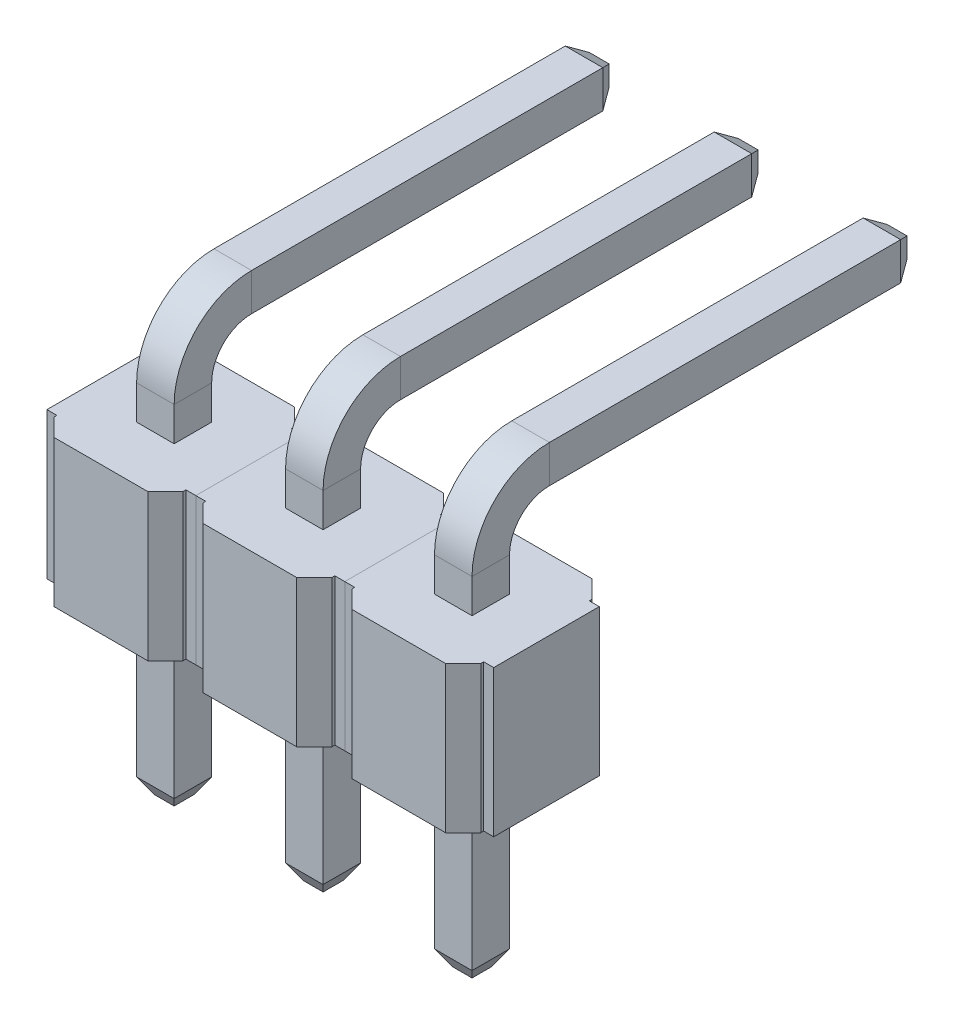
from build123d import *

# Parameters (mm, degrees)
SKETCH_3_W                   = 0.64
SKETCH_3_H                   = 0.64
END_PIN_PROFILE_SIZE         = 0.15
END_PIN_PROFILE_SIZE2        = 0.259807621
END_PIN_PROFILE_PART_2_SIZE  = 0.15
END_PIN_PROFILE_PART_2_SIZE2 = 0.259807621
BASE_BODY_DEPTH              = 2.5
BB_CHAMFER_SIZE              = 0.3
LP_ALL_COUNT                 = 2
LP_ALL_PITCH                 = 2.54
LP_ALL_2_COUNT               = 2
LP_ALL_2_PITCH               = 2.54


with BuildPart() as part:
    # PIN PROFILE: sweep along a path in Эскиз2
    with BuildLine(Plane(origin=(0, 0, 0), x_dir=(0, 0, -1), z_dir=(1, 0, 0))) as pin_profile_path:
        Line((0, -3), (0, 0))
        Line((0, 0), (0, 3.08))
        ThreePointArc((0, 3.08), (0.292893219, 3.787106781), (1, 4.08))
        Line((1, 4.08), (7.25, 4.08))
    # Эскиз3 → PIN PROFILE (sweep)
    with BuildSketch(Plane(origin=(0, 0, 0), x_dir=(1, 0, 0), z_dir=(0, 1, 0))):
        Rectangle(SKETCH_3_W, SKETCH_3_H)
    sweep(path=pin_profile_path.line)

    # END PIN PROFILE
    end_pin_profile_edges = [part.edges().sort_by_distance(p)[0] for p in [
        (0, 3.76, -7.25),
        (-0.32, 4.08, -7.25),
        (0, 4.4, -7.25),
        (0.32, 4.08, -7.25),
    ]]
    end_pin_profile_side = [part.faces().sort_by_distance(p)[0] for p in [
        (0, 4.08, -7.25),
    ]]
    chamfer(end_pin_profile_edges, length=END_PIN_PROFILE_SIZE, length2=END_PIN_PROFILE_SIZE2, reference=end_pin_profile_side[0])

    # END PIN PROFILE part 2
    end_pin_profile_part_2_edges = [part.edges().sort_by_distance(p)[0] for p in [
        (0.32, -3, 0),
        (0, -3, -0.32),
        (-0.32, -3, 0),
        (0, -3, 0.32),
    ]]
    end_pin_profile_part_2_side = [part.faces().sort_by_distance(p)[0] for p in [
        (0, -3, 0),
    ]]
    chamfer(end_pin_profile_part_2_edges, length=END_PIN_PROFILE_PART_2_SIZE, length2=END_PIN_PROFILE_PART_2_SIZE2, reference=end_pin_profile_part_2_side[0])


with BuildPart() as body_2:
    # Эскиз4 → BASE BODY (new body)
    with BuildSketch(Plane(origin=(0, 0, 0), x_dir=(1, 0, 0), z_dir=(0, 1, 0))):
        Polygon((-1.1, 0.9), (-1.1, 1.25), (1.1, 1.25), (1.1, 0.9), (1.27, 0.9), (1.27, -0.9), (1.1, -0.9), (1.1, -1.25), (-1.1, -1.25), (-1.1, -0.9), (-1.27, -0.9), (-1.27, 0.9), align=None)
    extrude(amount=BASE_BODY_DEPTH)

    # BB CHAMFER
    bb_chamfer_edges = [body_2.edges().sort_by_distance(p)[0] for p in [
        (1.1, 1.25, 1.25),
        (-1.1, 1.25, 1.25),
        (-1.1, 1.25, -1.25),
        (1.1, 1.25, -1.25),
    ]]
    chamfer(bb_chamfer_edges, length=BB_CHAMFER_SIZE)


with BuildPart() as lp_all_1:
    # LP ALL: pattern copy
    add(body_2.part.moved(Location(Vector(-1, 0, 0) * (1 * LP_ALL_PITCH))))


with BuildPart() as lp_all_2:
    # LP ALL: pattern copy
    add(part.part.moved(Location(Vector(-1, 0, 0) * (1 * LP_ALL_PITCH))))


with BuildPart() as lp_all_2_1:
    # LP ALL 2: pattern copy
    add(body_2.part.moved(Location(Vector(1, 0, 0) * (1 * LP_ALL_2_PITCH))))


with BuildPart() as lp_all_2_2:
    # LP ALL 2: pattern copy
    add(part.part.moved(Location(Vector(1, 0, 0) * (1 * LP_ALL_2_PITCH))))


solid = Compound([part.part, body_2.part, lp_all_1.part, lp_all_2.part, lp_all_2_1.part, lp_all_2_2.part])
